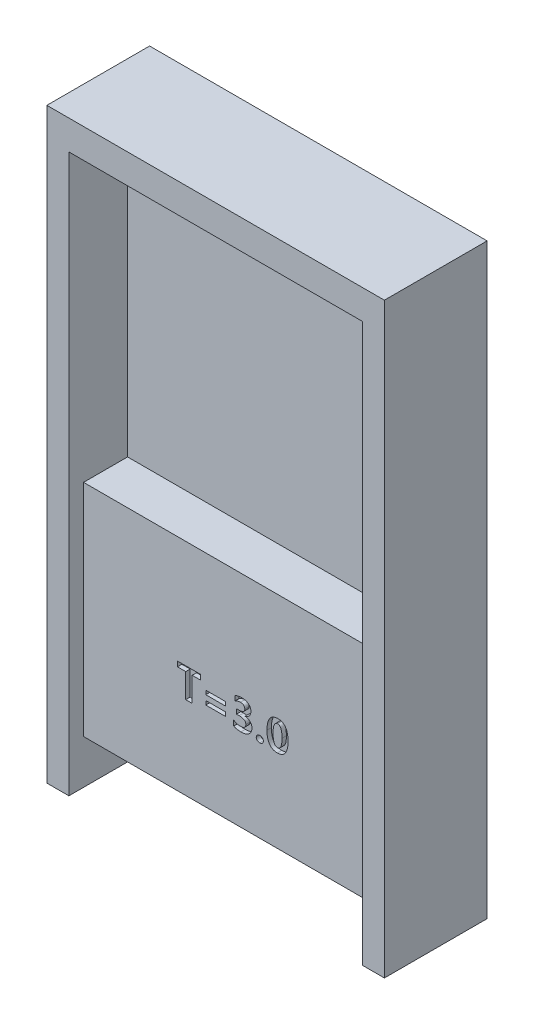
from build123d import *

# Parameters (mm, degrees)
EXTRUDE_1_DEPTH     = 7
SKETCH_2_W          = 20
SKETCH_2_H          = 35
EXTRUDE_2_DEPTH     = 6
SKETCH_3_W          = 20
SKETCH_3_H          = 20
CUT_EXTRUDE_1_DEPTH = 3
SKETCH_4_W          = 14
SKETCH_4_H          = 10
CUT_EXTRUDE_2_DEPTH = 5
SKETCH_5_W          = 1.341463414
SKETCH_5_H          = 0.268292683
CUT_EXTRUDE_3_DEPTH = 0.3


with BuildPart() as part:
    # 草图1 → 凸台-拉伸1 (new body)
    with BuildSketch(Plane.XY):
        Polygon((-10, 0), (-10, -18), (-11.5, -18), (-11.5, 22), (11.5, 22), (11.5, -18), (10, -18), (10, 0), (10, 20), (-10, 20), align=None)
    extrude(amount=EXTRUDE_1_DEPTH)

    # 草图2 → 凸台-拉伸2 (add)
    with BuildSketch(Plane.XY):
        with Locations((0, 2.5)):
            Rectangle(SKETCH_2_W, SKETCH_2_H)
    extrude(amount=EXTRUDE_2_DEPTH)

    # 草图3 → 切除-拉伸1 (cut)
    with BuildSketch(Plane.XY.offset(6)):
        with Locations((0, 10)):
            Rectangle(SKETCH_3_W, SKETCH_3_H)
    extrude(amount=-CUT_EXTRUDE_1_DEPTH, mode=Mode.SUBTRACT)

    # 草图4 → 切除-拉伸2 (cut)
    with BuildSketch(Plane(origin=(0, 0, 0), x_dir=(-1, 0, 0), z_dir=(0, 0, -1))):
        with Locations((0, -7)):
            Rectangle(SKETCH_4_W, SKETCH_4_H)
    extrude(amount=-CUT_EXTRUDE_2_DEPTH, mode=Mode.SUBTRACT)

    # 草图5 → 切除-拉伸3 (cut)
    with BuildSketch(Plane.XY.offset(6)):
        Polygon((-2.038957757, -7.685646489), (-2.599933366, -7.685646489), (-2.599933366, -9.344183074), (-3.038957757, -9.344183074), (-3.038957757, -7.685646489), (-3.599933366, -7.685646489), (-3.599933366, -7.344183074), (-2.038957757, -7.344183074), align=None)
        with Locations((-1.002372391, -8.234426976)):
            Rectangle(SKETCH_5_W, SKETCH_5_H)
        with Locations((-1.002372391, -8.844183075)):
            Rectangle(SKETCH_5_W, SKETCH_5_H)
        with BuildLine():
            add(Edge.make_bspline(
                [(0.229334926, -8.905158684), (0.24604363, -8.916880807), (0.279245516, -8.940173853), (0.332236805, -8.969903263), (0.38727932, -8.995190837), (0.444554224, -9.015733146), (0.503815093, -9.031793104), (0.56510902, -9.043190831), (0.628433338, -9.050222337), (0.671389872, -9.051070754), (0.693130658, -9.051500147)],
                knots=[0, 0, 0, 0, 6.12e-05, 0.000121611, 0.000181979, 0.000242735, 0.000303935, 0.000365973, 0.000429606, 0.000494814, 0.000494814, 0.000494814, 0.000494814], degree=3))
            add(Edge.make_bspline(
                [(0.693130658, -9.051500147), (0.7067291, -9.051279465), (0.733335795, -9.050847677), (0.772206094, -9.047516785), (0.80899179, -9.041343711), (0.843490925, -9.033012784), (0.875971389, -9.022759348), (0.906189985, -9.00989128), (0.933997474, -8.993982221), (0.960036299, -8.976661956), (0.983475991, -8.95696309), (1.003270106, -8.934449983), (1.020730017, -8.910565745), (1.03431802, -8.884194243), (1.04565488, -8.856368241), (1.053118293, -8.826208533), (1.057787842, -8.794153249), (1.058327048, -8.772045726), (1.058603219, -8.760722708)],
                knots=[0, 0, 0, 0, 4.0793e-05, 7.9816e-05, 0.000116906, 0.000152585, 0.000186211, 0.000218987, 0.000250895, 0.000282182, 0.000312729, 0.000342416, 0.000371921, 0.000401243, 0.000431178, 0.000461865, 0.000494202, 0.000528154, 0.000528154, 0.000528154, 0.000528154], degree=3))
            add(Edge.make_bspline(
                [(1.058603219, -8.760722708), (1.058260378, -8.749137018), (1.057589137, -8.726453653), (1.051668517, -8.693587036), (1.042530968, -8.662703709), (1.0297562, -8.633818842), (1.011961013, -8.607742703), (0.9914933, -8.583252165), (0.967168182, -8.560756241), (0.938723478, -8.541336241), (0.907563158, -8.523200111), (0.872945381, -8.508103676), (0.835477115, -8.495143156), (0.794949232, -8.484529849), (0.751521409, -8.476271936), (0.705098068, -8.47007379), (0.655704644, -8.466787366), (0.621742793, -8.466355603), (0.604334926, -8.466134294)],
                knots=[0, 0, 0, 0, 3.4732e-05, 6.8001e-05, 9.9832e-05, 0.000131214, 0.000162289, 0.000194201, 0.000226836, 0.000261303, 0.000297323, 0.000334856, 0.000374388, 0.00041617, 0.000460417, 0.000506931, 0.000556592, 0.000608815, 0.000608815, 0.000608815, 0.000608815], degree=3))
            Line((0.604334926, -8.466134294), (0.424456877, -8.466134294))
            Line((0.424456877, -8.466134294), (0.424456877, -8.149061123))
            Line((0.424456877, -8.149061123), (0.586804438, -8.149061123))
            add(Edge.make_bspline(
                [(0.586804438, -8.149061123), (0.602942894, -8.1488315), (0.634106366, -8.148388096), (0.679254902, -8.145284918), (0.721394676, -8.140460756), (0.760544214, -8.133419324), (0.796360879, -8.123747882), (0.829245189, -8.112804901), (0.8590528, -8.099518007), (0.885797441, -8.083960188), (0.909285494, -8.066254257), (0.929839752, -8.046710622), (0.946970327, -8.024797058), (0.961444521, -8.001010618), (0.971834252, -7.97473958), (0.980083085, -7.946870878), (0.984599071, -7.916737583), (0.985148861, -7.896026208), (0.985432487, -7.885341611)],
                knots=[0, 0, 0, 0, 4.8413e-05, 9.3486e-05, 0.000135698, 0.000175613, 0.000212682, 0.000246909, 0.00027949, 0.000310406, 0.000339522, 0.000367552, 0.000395228, 0.000422744, 0.00045077, 0.000479718, 0.000509793, 0.000541842, 0.000541842, 0.000541842, 0.000541842], degree=3))
            add(Edge.make_bspline(
                [(0.985432487, -7.885341611), (0.98521461, -7.875298349), (0.984791289, -7.855784977), (0.98147192, -7.82740068), (0.975249908, -7.801185587), (0.967314617, -7.776667253), (0.956705718, -7.754233459), (0.943444365, -7.733776583), (0.928336657, -7.715007914), (0.910469966, -7.698386673), (0.890150564, -7.683939665), (0.867596087, -7.671436384), (0.842885385, -7.660594254), (0.815669443, -7.651893883), (0.786068829, -7.645211678), (0.754259415, -7.640121518), (0.720099014, -7.637683728), (0.696563294, -7.637145137), (0.684365414, -7.636866001)],
                knots=[0, 0, 0, 0, 3.0128e-05, 5.8537e-05, 8.5531e-05, 0.000110839, 0.000135727, 0.000159724, 0.00018383, 0.000207827, 0.00023268, 0.000258443, 0.000285065, 0.000313508, 0.000344014, 0.000376031, 0.000410054, 0.000446657, 0.000446657, 0.000446657, 0.000446657], degree=3))
            add(Edge.make_bspline(
                [(0.684365414, -7.636866001), (0.667960747, -7.637224229), (0.635305691, -7.637937315), (0.58651503, -7.643959771), (0.538201923, -7.653358142), (0.490220507, -7.666919374), (0.442563091, -7.684046917), (0.395235901, -7.705150046), (0.348179013, -7.729866822), (0.317876472, -7.749074315), (0.302505658, -7.758817221)],
                knots=[0, 0, 0, 0, 4.9198e-05, 9.7934e-05, 0.000147263, 0.000196732, 0.000247362, 0.000299058, 0.000352076, 0.000406653, 0.000406653, 0.000406653, 0.000406653], degree=3))
            Line((0.302505658, -7.758817221), (0.302505658, -7.423832464))
            add(Edge.make_bspline(
                [(0.302505658, -7.423832464), (0.31953664, -7.415437213), (0.353820338, -7.398537409), (0.407874987, -7.377843206), (0.463977304, -7.359874483), (0.522362193, -7.344966095), (0.583082884, -7.333534013), (0.645971109, -7.325768166), (0.711079764, -7.320508043), (0.755238764, -7.320034211), (0.777734316, -7.31979283)],
                knots=[0, 0, 0, 0, 5.6937e-05, 0.000114615, 0.00017343, 0.000233602, 0.000295266, 0.000358654, 0.00042363, 0.000491102, 0.000491102, 0.000491102, 0.000491102], degree=3))
            add(Edge.make_bspline(
                [(0.777734316, -7.31979283), (0.800234972, -7.320104024), (0.844306766, -7.320713554), (0.908833113, -7.327091709), (0.970279143, -7.336719768), (1.02842773, -7.350800466), (1.08308782, -7.369133837), (1.134453289, -7.391343649), (1.182783062, -7.417287033), (1.227512683, -7.44719592), (1.268191755, -7.480605751), (1.303284786, -7.517776978), (1.333503076, -7.55774167), (1.358070691, -7.601016275), (1.376642495, -7.647667315), (1.390613526, -7.697160211), (1.398565678, -7.749921341), (1.399559821, -7.786103388), (1.400066634, -7.804548928)],
                knots=[0, 0, 0, 0, 6.7481e-05, 0.000132175, 0.000194326, 0.000253945, 0.00031143, 0.000367075, 0.00042164, 0.000475757, 0.00052826, 0.000579209, 0.000628752, 0.000678243, 0.000727994, 0.000779034, 0.000832231, 0.000887554, 0.000887554, 0.000887554, 0.000887554], degree=3))
            add(Edge.make_bspline(
                [(1.400066634, -7.804548928), (1.39979498, -7.820187374), (1.39926151, -7.850897967), (1.394468702, -7.895690947), (1.387512743, -7.938475899), (1.37668369, -7.978667156), (1.363457368, -8.016953969), (1.346516292, -8.052641689), (1.327148733, -8.086485139), (1.304363933, -8.117860803), (1.279005211, -8.147363385), (1.249991928, -8.173943826), (1.218703705, -8.199104917), (1.18390337, -8.22131808), (1.146302281, -8.241800654), (1.1055194, -8.259435749), (1.061910579, -8.275293936), (1.031486377, -8.283554329), (1.015920292, -8.287780635)],
                knots=[0, 0, 0, 0, 4.69e-05, 9.2101e-05, 0.000135018, 0.0001768, 0.000216817, 0.000256371, 0.000295132, 0.000333631, 0.000372529, 0.000411626, 0.000451503, 0.000492834, 0.000535294, 0.000579832, 0.000626001, 0.000674371, 0.000674371, 0.000674371, 0.000674371], degree=3))
            Line((1.015920292, -8.287780635), (1.015920292, -8.294259294))
            add(Edge.make_bspline(
                [(1.015920292, -8.294259294), (1.032856699, -8.296556474), (1.066046779, -8.301058231), (1.11435111, -8.311846295), (1.160066117, -8.325758061), (1.203135457, -8.343481155), (1.243525662, -8.364454895), (1.28153257, -8.388507809), (1.316786561, -8.416067505), (1.348902733, -8.446965715), (1.378354442, -8.479815456), (1.40361904, -8.515173687), (1.424990411, -8.5522194), (1.442717201, -8.590977937), (1.456370851, -8.63148463), (1.466433097, -8.673675208), (1.472162852, -8.717753555), (1.472875041, -8.747749132), (1.473237365, -8.763009294)],
                knots=[0, 0, 0, 0, 5.1256e-05, 0.000100445, 0.000148302, 0.000194444, 0.000239955, 0.000284675, 0.000329197, 0.000373943, 0.000418219, 0.000461369, 0.000504054, 0.000546348, 0.000589011, 0.000632087, 0.000676284, 0.000722056, 0.000722056, 0.000722056, 0.000722056], degree=3))
            add(Edge.make_bspline(
                [(1.473237365, -8.763009294), (1.472752056, -8.786169471), (1.47180334, -8.83144459), (1.461480294, -8.897195603), (1.445585897, -8.959238571), (1.423097099, -9.017395521), (1.394001898, -9.071631499), (1.357957158, -9.121429408), (1.316378224, -9.168071028), (1.267782937, -9.20957196), (1.214242758, -9.246981798), (1.156278074, -9.279874229), (1.09374585, -9.307260864), (1.027171816, -9.329764305), (0.956287775, -9.347255309), (0.881131952, -9.359788538), (0.801627432, -9.36691946), (0.747260587, -9.368013303), (0.71942639, -9.368573318)],
                knots=[0, 0, 0, 0, 6.9427e-05, 0.00013572, 0.00019913, 0.000261268, 0.000322311, 0.000383226, 0.00044529, 0.00050932, 0.000574447, 0.000641002, 0.000708912, 0.000778931, 0.000851581, 0.000927703, 0.001007301, 0.001090804, 0.001090804, 0.001090804, 0.001090804], degree=3))
            add(Edge.make_bspline(
                [(0.71942639, -9.368573318), (0.694643907, -9.368346033), (0.646296819, -9.367902631), (0.575755058, -9.362563045), (0.508894514, -9.355378984), (0.445827237, -9.344129147), (0.38614612, -9.33029069), (0.330368186, -9.312626893), (0.277857486, -9.292748331), (0.245334151, -9.276135784), (0.229334926, -9.267963562)],
                knots=[0, 0, 0, 0, 7.433e-05, 0.000145007, 0.000212133, 0.000275978, 0.000337078, 0.000395778, 0.000451404, 0.000505263, 0.000505263, 0.000505263, 0.000505263], degree=3))
            Line((0.229334926, -9.267963562), (0.229334926, -8.905158684))
        make_face()
        with BuildLine():
            add(Edge.make_bspline(
                [(1.765920292, -9.148298928), (1.766728688, -9.13293706), (1.768306553, -9.10295307), (1.782811043, -9.060401528), (1.805672247, -9.022074277), (1.837676301, -8.989577343), (1.875610321, -8.963244909), (1.91772659, -8.943269281), (1.963730332, -8.93166491), (1.995531011, -8.93026298), (2.011728219, -8.929548928)],
                knots=[0, 0, 0, 0, 4.596e-05, 8.9706e-05, 0.0001333, 0.000178849, 0.000225368, 0.000271229, 0.000317999, 0.000366548, 0.000366548, 0.000366548, 0.000366548], degree=3))
            add(Edge.make_bspline(
                [(2.011728219, -8.929548928), (2.028065988, -8.930204709), (2.05992891, -8.931483653), (2.105735531, -8.943744006), (2.147528564, -8.963762738), (2.18423842, -8.991316277), (2.215381989, -9.023891566), (2.237566329, -9.062037881), (2.251651901, -9.103881831), (2.253026177, -9.133323908), (2.25372517, -9.148298928)],
                knots=[0, 0, 0, 0, 4.8929e-05, 9.5425e-05, 0.000141105, 0.000187143, 0.000232444, 0.00027532, 0.000318586, 0.000363371, 0.000363371, 0.000363371, 0.000363371], degree=3))
            add(Edge.make_bspline(
                [(2.25372517, -9.148298928), (2.253059897, -9.164038906), (2.251767619, -9.194613446), (2.237626519, -9.237827101), (2.215707139, -9.276743138), (2.184233619, -9.309179905), (2.147084973, -9.336108296), (2.104121523, -9.354752487), (2.056955565, -9.366632061), (2.023871778, -9.367911895), (2.006773951, -9.368573318)],
                knots=[0, 0, 0, 0, 4.7062e-05, 9.1417e-05, 0.000134952, 0.000179975, 0.000225872, 0.000271763, 0.000319642, 0.000370851, 0.000370851, 0.000370851, 0.000370851], degree=3))
            add(Edge.make_bspline(
                [(2.006773951, -9.368573318), (1.990685107, -9.367928817), (1.959312571, -9.366672068), (1.914249958, -9.354238924), (1.872689627, -9.334587328), (1.835651356, -9.307320667), (1.804757726, -9.274061435), (1.781858097, -9.235889571), (1.768574281, -9.193232366), (1.766818533, -9.163506622), (1.765920292, -9.148298928)],
                knots=[0, 0, 0, 0, 4.8169e-05, 9.3928e-05, 0.0001391, 0.000185444, 0.000231025, 0.000274423, 0.000317937, 0.000363517, 0.000363517, 0.000363517, 0.000363517], degree=3))
        make_face()
        with BuildLine():
            add(Edge.make_bspline(
                [(2.497627609, -8.376195269), (2.498230233, -8.33464218), (2.499401877, -8.253853166), (2.507935403, -8.136474627), (2.523257169, -8.026666137), (2.543957517, -7.924494932), (2.570431815, -7.82963793), (2.603539961, -7.742666222), (2.642506018, -7.663044715), (2.687420852, -7.591114942), (2.738230473, -7.527107963), (2.794453931, -7.471292359), (2.856427318, -7.424387451), (2.923674341, -7.385964838), (2.996325018, -7.356118715), (3.074234537, -7.334776161), (3.157523848, -7.32205823), (3.214807974, -7.320560992), (3.244197731, -7.31979283)],
                knots=[0, 0, 0, 0, 0.000124656, 0.000242361, 0.000352793, 0.000457056, 0.000554894, 0.000647895, 0.00073584, 0.00082043, 0.00090179, 0.000980479, 0.001057462, 0.001134275, 0.001212195, 0.001292447, 0.001376096, 0.001464229, 0.001464229, 0.001464229, 0.001464229], degree=3))
            add(Edge.make_bspline(
                [(3.244197731, -7.31979283), (3.272188336, -7.320454731), (3.326656093, -7.321742742), (3.40556172, -7.333729971), (3.479155402, -7.353532371), (3.547305111, -7.381394564), (3.610203574, -7.417109594), (3.66731398, -7.461027231), (3.719369716, -7.512602014), (3.765440046, -7.572474148), (3.806041453, -7.640202958), (3.840792411, -7.715765572), (3.871231096, -7.79870889), (3.89465707, -7.889985846), (3.913746585, -7.988857083), (3.927247967, -8.095650511), (3.93522796, -8.210294457), (3.936167079, -8.289291677), (3.936651999, -8.330082464)],
                knots=[0, 0, 0, 0, 8.3928e-05, 0.000163318, 0.000238757, 0.000312076, 0.000383594, 0.000455091, 0.000527581, 0.00060282, 0.000681118, 0.000763978, 0.000851986, 0.000945811, 0.001046338, 0.001153923, 0.001268532, 0.001390894, 0.001390894, 0.001390894, 0.001390894], degree=3))
            add(Edge.make_bspline(
                [(3.936651999, -8.330082464), (3.936078467, -8.370369234), (3.934964346, -8.448628653), (3.926028121, -8.562499037), (3.911921795, -8.669355116), (3.891418027, -8.769247732), (3.86484227, -8.862031598), (3.832528954, -8.94779122), (3.794366517, -9.026531177), (3.750285056, -9.097881664), (3.700560757, -9.161660234), (3.645584346, -9.217253621), (3.585208639, -9.264531097), (3.518975101, -9.302204726), (3.448027235, -9.332214433), (3.37176209, -9.353641392), (3.290226755, -9.366282859), (3.234080484, -9.367797573), (3.20532578, -9.368573318)],
                knots=[0, 0, 0, 0, 0.000120846, 0.000234751, 0.000342437, 0.00044401, 0.000540382, 0.000631688, 0.000718612, 0.000802475, 0.000882828, 0.000960707, 0.001036481, 0.001112112, 0.001188625, 0.001267042, 0.001349185, 0.001435415, 0.001435415, 0.001435415, 0.001435415], degree=3))
            add(Edge.make_bspline(
                [(3.20532578, -9.368573318), (3.176697592, -9.367928702), (3.121086839, -9.366676523), (3.040492389, -9.354482679), (2.96536629, -9.335312264), (2.895724029, -9.308057618), (2.831433459, -9.273186689), (2.772769474, -9.230324846), (2.720045831, -9.179150151), (2.672642567, -9.12059726), (2.631000854, -9.054116075), (2.595194597, -8.979897861), (2.564766207, -8.898106694), (2.540293114, -8.808510441), (2.520805095, -8.711369853), (2.507553962, -8.606420119), (2.498913399, -8.493845677), (2.49806512, -8.416227709), (2.497627609, -8.376195269)],
                knots=[0, 0, 0, 0, 8.5832e-05, 0.000166729, 0.000243912, 0.000318008, 0.000390486, 0.000462747, 0.000535249, 0.000610302, 0.000688227, 0.000770039, 0.000857106, 0.000949659, 0.00104839, 0.001154086, 0.001266822, 0.001386897, 0.001386897, 0.001386897, 0.001386897], degree=3))
        make_face()
        with BuildLine():
            add(Edge.make_bspline(
                [(2.912261755, -8.365905635), (2.912417692, -8.39360479), (2.912719713, -8.447252922), (2.916828949, -8.524889783), (2.922221966, -8.597260998), (2.930469688, -8.664315304), (2.941590032, -8.72595059), (2.954360971, -8.782418994), (2.969672169, -8.833521131), (2.988282903, -8.879062592), (3.008004884, -8.919818674), (3.031082191, -8.954799948), (3.056430751, -8.984647806), (3.084237425, -9.009331136), (3.114831663, -9.028304927), (3.147659342, -9.041768667), (3.182938181, -9.050088808), (3.207311765, -9.051021817), (3.219807487, -9.051500147)],
                knots=[0, 0, 0, 0, 8.3087e-05, 0.000160924, 0.000233178, 0.000300773, 0.000363493, 0.000420993, 0.000474397, 0.000523298, 0.000568462, 0.000610002, 0.000648651, 0.000685649, 0.000721077, 0.000756109, 0.0007917, 0.000829143, 0.000829143, 0.000829143, 0.000829143], degree=3))
            add(Edge.make_bspline(
                [(3.219807487, -9.051500147), (3.232054803, -9.051044613), (3.256090741, -9.050150606), (3.290746144, -9.041417208), (3.32310727, -9.027469832), (3.352966, -9.007822508), (3.380401064, -8.982536814), (3.405129028, -8.951677157), (3.427585898, -8.915533097), (3.447871619, -8.874087397), (3.465211652, -8.826879658), (3.480140971, -8.774183385), (3.493766246, -8.716290847), (3.503540338, -8.652654854), (3.512036095, -8.58366258), (3.518050044, -8.509034943), (3.521389094, -8.428945287), (3.521803864, -8.37378486), (3.522017853, -8.345326367)],
                knots=[0, 0, 0, 0, 3.6682e-05, 7.1991e-05, 0.000106469, 0.000141985, 0.00017867, 0.000217952, 0.000260247, 0.000306095, 0.000356141, 0.000410897, 0.000470339, 0.000534433, 0.000603919, 0.000678863, 0.000758967, 0.00084434, 0.00084434, 0.00084434, 0.00084434], degree=3))
            add(Edge.make_bspline(
                [(3.522017853, -8.345326367), (3.521812706, -8.316740336), (3.52141502, -8.261324969), (3.517960563, -8.180998139), (3.512387699, -8.106242247), (3.504397954, -8.037079025), (3.494394144, -7.97327604), (3.481339759, -7.915074789), (3.466762486, -7.862246785), (3.44958859, -7.815078633), (3.430305151, -7.773171344), (3.408384616, -7.736902467), (3.383975207, -7.706238424), (3.357713411, -7.680546194), (3.32844861, -7.660936371), (3.296870538, -7.646946085), (3.263083127, -7.638248179), (3.239676413, -7.637330973), (3.227810536, -7.636866001)],
                knots=[0, 0, 0, 0, 8.5755e-05, 0.000166239, 0.000241153, 0.000310594, 0.000375064, 0.000434794, 0.000489445, 0.000539359, 0.000585221, 0.000627639, 0.000666147, 0.000702535, 0.000737416, 0.000771196, 0.000805765, 0.000841307, 0.000841307, 0.000841307, 0.000841307], degree=3))
            add(Edge.make_bspline(
                [(3.227810536, -7.636866001), (3.215048074, -7.63728457), (3.189965152, -7.638107212), (3.153861293, -7.647395754), (3.119906889, -7.661471852), (3.088936845, -7.682219799), (3.060000918, -7.707953809), (3.033999343, -7.739686369), (3.010795822, -7.777108501), (2.989918812, -7.820071396), (2.971285676, -7.868633588), (2.955410165, -7.92295479), (2.942276735, -7.982972938), (2.931339585, -8.048613852), (2.922545915, -8.119933845), (2.916757897, -8.196876374), (2.912735513, -8.279480713), (2.91242334, -8.336428731), (2.912261755, -8.365905635)],
                knots=[0, 0, 0, 0, 3.8203e-05, 7.5083e-05, 0.000111112, 0.000148002, 0.000186328, 0.000226926, 0.000270594, 0.000318146, 0.000370023, 0.000426456, 0.000487757, 0.000554231, 0.000626033, 0.000703256, 0.000785661, 0.000874083, 0.000874083, 0.000874083, 0.000874083], degree=3))
        make_face(mode=Mode.SUBTRACT)
    extrude(amount=-CUT_EXTRUDE_3_DEPTH, mode=Mode.SUBTRACT)


solid = part.part
